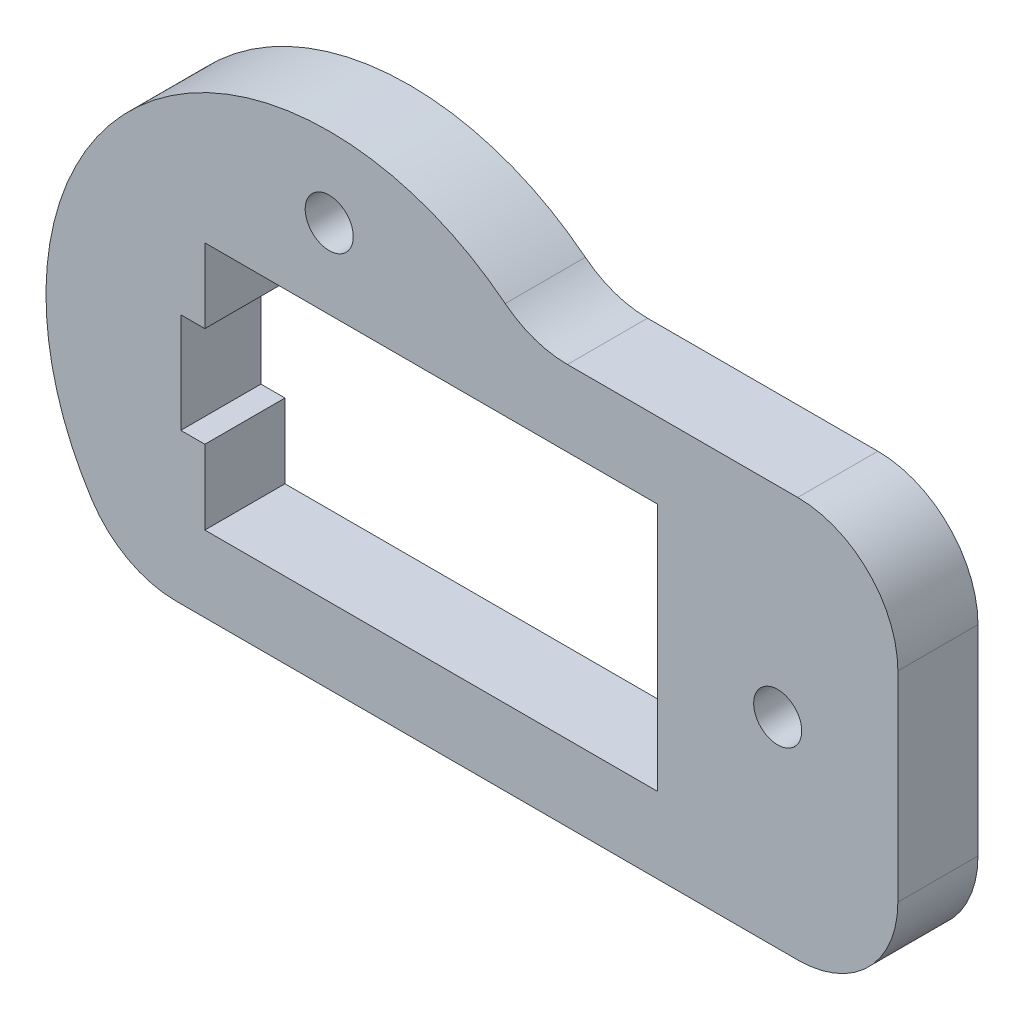
from build123d import *

# Parameters (mm, degrees)
SKETCH1_R           = 1.2
BOSS_EXTRUDE1_DEPTH = 4
FILLET1_R           = 5


with BuildPart() as part:
    # Sketch1 → Boss-Extrude1 (new body)
    with BuildSketch(Plane.XY):
        with BuildLine():
            Line((0, 0), (38.39, 0))
            Line((38.39, 0), (38.39, 20))
            Line((38.39, 20), (20, 20))
            ThreePointArc((20, 20), (0, 20), (0, 0))
        make_face()
        Polygon((3.79, 3.79), (3.79, 7.5), (2.59, 7.5), (2.59, 12.5), (3.79, 12.5), (3.79, 16.21), (26.39, 16.21), (26.39, 3.79), align=None, mode=Mode.SUBTRACT)
        with Locations((10, 20.176067812)):
            Circle(SKETCH1_R, mode=Mode.SUBTRACT)
        with Locations((32.39, 10)):
            Circle(SKETCH1_R, mode=Mode.SUBTRACT)
    extrude(amount=BOSS_EXTRUDE1_DEPTH)

    # Fillet1
    fillet1_edges = [part.edges().sort_by_distance(p)[0] for p in [
        (38.39, 20, 2),
        (38.39, 0, 2),
        (0, 0, 2),
        (20, 20, 2),
    ]]
    fillet(fillet1_edges, radius=FILLET1_R)


solid = part.part
